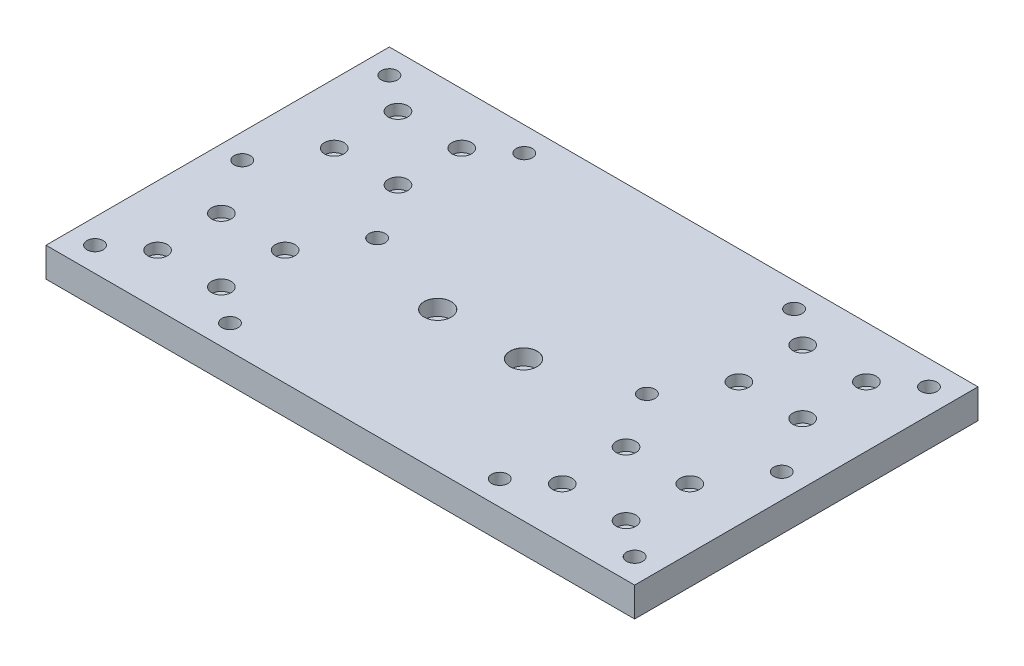
from build123d import *

# Parameters (mm, degrees)
SKETCH2_W                                           = 240
SKETCH2_H                                           = 140
EXTRUDE1_DEPTH                                      = 12
CBORE_FOR_M4_HEX_SOCKET_HEAD_CAP_SCREW1_D           = 4.5
CBORE_FOR_M4_HEX_SOCKET_HEAD_CAP_SCREW1_CBORE_D     = 8
CBORE_FOR_M4_HEX_SOCKET_HEAD_CAP_SCREW1_CBORE_DEPTH = 4.4
CBORE_FOR_M6_HEX_SOCKET_HEAD_CAP_SCREW1_D           = 6.6
CBORE_FOR_M6_HEX_SOCKET_HEAD_CAP_SCREW1_CBORE_D     = 11
CBORE_FOR_M6_HEX_SOCKET_HEAD_CAP_SCREW1_CBORE_DEPTH = 6.4
CBORE_FOR_M6_HEX_SOCKET_HEAD_CAP_SCR_2_COUNT        = 2
CBORE_FOR_M6_HEX_SOCKET_HEAD_CAP_SCR_2_PITCH        = 35


with BuildPart() as part:
    # Sketch2 → Extrude1 (new body)
    with BuildSketch(Plane(origin=(0, 0, 0), x_dir=(1, 0, 0), z_dir=(0, 1, 0))):
        Rectangle(SKETCH2_W, SKETCH2_H)
    extrude(amount=EXTRUDE1_DEPTH)

    # CBORE for M4 Hex Socket Head Cap Screw1 (through all)
    with Locations(Plane(origin=(0, 12, 0), x_dir=(1, 0, 0), z_dir=(0, 1, 0))):
        with Locations((-95.5, 49), (-69.5, 49), (-69.5, 23), (-95.5, 23), (-95.5, -23), (-69.5, -23), (-69.5, -49), (-95.5, -49), (69.5, 49), (95.5, 49), (95.5, 23), (69.5, 23), (69.5, -23), (95.5, -23), (95.5, -49), (69.5, -49)):
            CounterBoreHole(CBORE_FOR_M4_HEX_SOCKET_HEAD_CAP_SCREW1_D / 2, CBORE_FOR_M4_HEX_SOCKET_HEAD_CAP_SCREW1_CBORE_D / 2, CBORE_FOR_M4_HEX_SOCKET_HEAD_CAP_SCREW1_CBORE_DEPTH)

    # CBORE for M6 Hex Socket Head Cap Screw1 (through all)
    with Locations(Plane(origin=(0, 0, 0), x_dir=(-1, 0, 0), z_dir=(0, -1, 0))):
        with Locations((110, -60), (110, 0), (110, 60), (55, 60), (55, 0), (55, -60), (-55, -60), (-55, 0), (-55, 60), (-110, 60), (-110, 0), (-110, -60)):
            CounterBoreHole(CBORE_FOR_M6_HEX_SOCKET_HEAD_CAP_SCREW1_D / 2, CBORE_FOR_M6_HEX_SOCKET_HEAD_CAP_SCREW1_CBORE_D / 2, CBORE_FOR_M6_HEX_SOCKET_HEAD_CAP_SCREW1_CBORE_DEPTH)

    # Sketch10 → CBORE for M6 Hex Socket Head Cap Screw2 (revolve, cut)
    with BuildSketch(Plane(origin=(17.5, 12, 12.8), x_dir=(0, 0, 1), z_dir=(1, 0, 0))):
        Polygon((0, 0), (0, 13.482840043), (3.3, 11.5), (3.3, 6.4), (5.5, 6.4), (5.5, 0.025), (5.525, 0), align=None)
    cbore_for_m6_hex_socket_head_cap_screw2 = revolve(axis=Axis((17.5, 18.35, 12.8), (0, -1, 0)), mode=Mode.SUBTRACT)

    # CBORE for M6 Hex Socket Head Cap Scr 2: CBORE for M6 Hex Socket Head Cap Screw2 ×2
    with Locations(*[(-i * CBORE_FOR_M6_HEX_SOCKET_HEAD_CAP_SCR_2_PITCH, 0, 0) for i in range(1, CBORE_FOR_M6_HEX_SOCKET_HEAD_CAP_SCR_2_COUNT)]):
        add(cbore_for_m6_hex_socket_head_cap_screw2, mode=Mode.SUBTRACT)


solid = part.part
